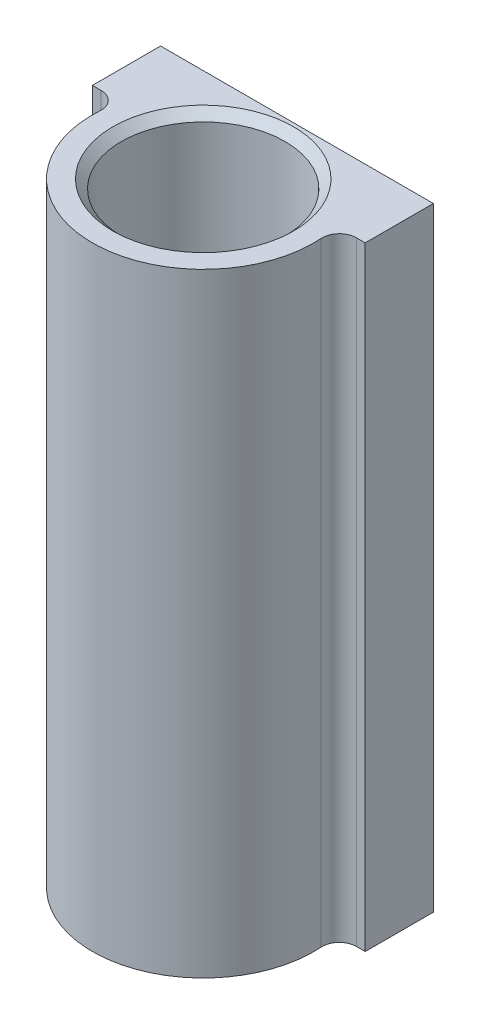
from build123d import *

# Parameters (mm, degrees)
SKETCH1_R           = 9.6
BOSS_EXTRUDE1_DEPTH = 72
SKETCH2_R           = 2.6
CUT_EXTRUDE1_DEPTH  = 6
CHAMFER1_SIZE       = 0.5
CHAMFER2_SIZE       = 1


with BuildPart() as part:
    # Sketch1 → Boss-Extrude1 (new body)
    with BuildSketch(Plane(origin=(0, 0, 0), x_dir=(1, 0, 0), z_dir=(0, 1, 0))):
        with BuildLine():
            Line((14.966629547, 3), (16, 3))
            Line((16, 3), (16, 11))
            Line((16, 11), (-16, 11))
            Line((-16, 11), (-16, 3))
            Line((-16, 3), (-14.966629547, 3))
            ThreePointArc((-14.966629547, 3), (-13.50603606, 2.366260102), (-12.971078941, 0.866666667))
            ThreePointArc((-12.971078941, 0.866666667), (0, -13), (12.971078941, 0.866666667))
            ThreePointArc((12.971078941, 0.866666667), (13.50603606, 2.366260102), (14.966629547, 3))
        make_face()
        with Locations(Location((0, 0, 0), (0, 0, 270))):  # turned: the seam where the file's is
            Circle(SKETCH1_R, mode=Mode.SUBTRACT)
    extrude(amount=BOSS_EXTRUDE1_DEPTH)

    # Sketch2 → Cut-Extrude1 (cut)
    with BuildSketch(Plane.XY.offset(-11)):
        with Locations((-11, 67)):
            Circle(SKETCH2_R)
        with Locations((-11, 5)):
            Circle(SKETCH2_R)
        with Locations((11, 67)):
            Circle(SKETCH2_R)
        with Locations((11, 5)):
            Circle(SKETCH2_R)
    extrude(amount=CUT_EXTRUDE1_DEPTH, mode=Mode.SUBTRACT)

    # Chamfer1
    chamfer1_edges = [part.edges().sort_by_distance(p)[0] for p in [
        (-13.6, 67, -11),
        (-13.6, 5, -11),
        (8.4, 67, -11),
        (8.4, 5, -11),
    ]]
    chamfer(chamfer1_edges, length=CHAMFER1_SIZE)

    # Chamfer2
    chamfer2_edges = [part.edges().sort_by_distance(p)[0] for p in [
        (0, 0, -9.6),
        (0, 72, -9.6),
    ]]
    chamfer(chamfer2_edges, length=CHAMFER2_SIZE)


solid = part.part
